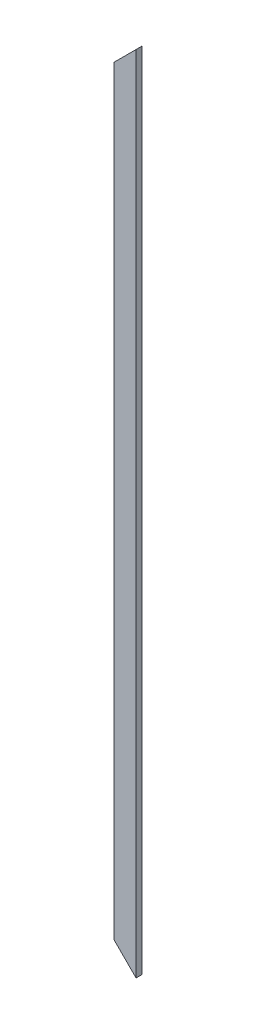
from build123d import *

# Parameters (mm, degrees)
SKETCH1_W               = 139.7
SKETCH1_H               = 38.1
BOSS_EXTRUDE1_DEPTH     = 5054.6
CUT_EXTRUDE1_DEPTH      = 1
CUT_EXTRUDE1_DEPTH_BACK = 39.1


with BuildPart() as part:
    # Sketch1 → Boss-Extrude1 (new body)
    with BuildSketch(Plane(origin=(0, 0, 0), x_dir=(1, 0, 0), z_dir=(0, 1, 0))):
        Rectangle(SKETCH1_W, SKETCH1_H)
    extrude(amount=BOSS_EXTRUDE1_DEPTH)

    # Sketch2 → Cut-Extrude1 (cut, two sides)
    with BuildSketch(Plane(origin=(0, 0, -19.05), x_dir=(-1, 0, 0), z_dir=(0, 0, -1))) as cut_extrude1_sk:
        Polygon((-69.85, 0), (69.85, 139.7), (69.85, 0), align=None)
        Polygon((-69.85, 5054.6), (69.85, 4914.9), (69.85, 5054.6), align=None)
    extrude(amount=CUT_EXTRUDE1_DEPTH, mode=Mode.SUBTRACT)
    extrude(cut_extrude1_sk.sketch, amount=-CUT_EXTRUDE1_DEPTH_BACK, mode=Mode.SUBTRACT)


solid = part.part
